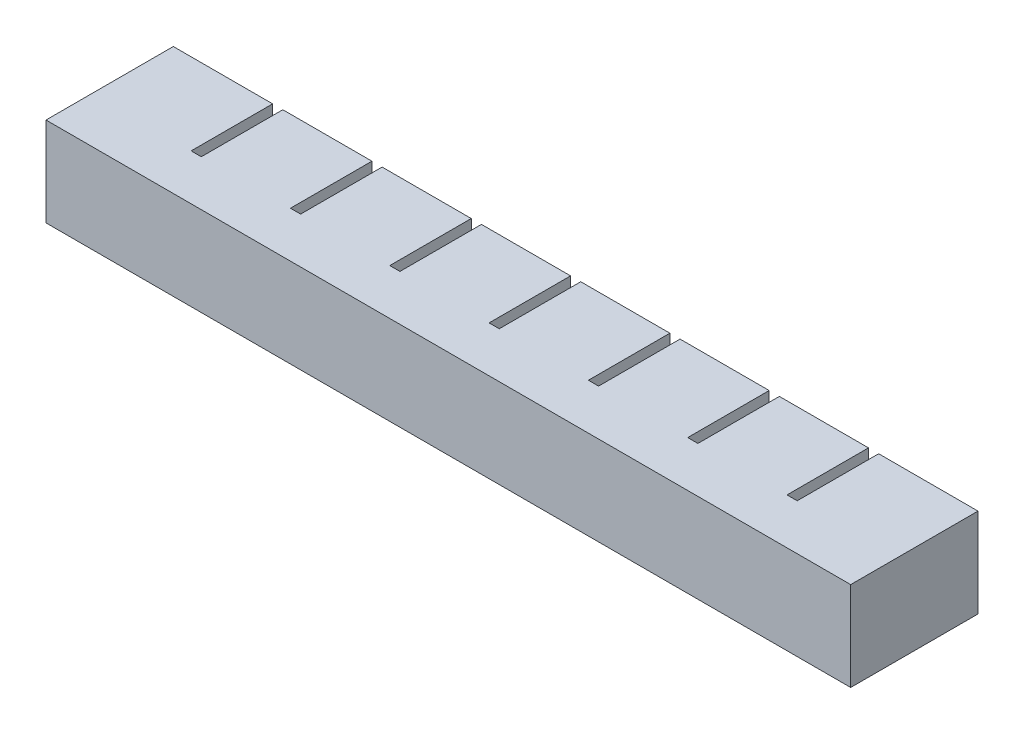
from build123d import *

# Parameters (mm, degrees)
SKETCH1_W           = 17.5
SKETCH1_H           = 17.5
BOSS_EXTRUDE1_DEPTH = 20
SKETCH2_W           = 11.5
SKETCH2_H           = 11.5
CUT_EXTRUDE1_DEPTH  = 17
SKETCH4_W           = 4
SKETCH4_H           = 17.5
BOSS_EXTRUDE2_DEPTH = 2
LPATTERN1_COUNT     = 8
LPATTERN1_PITCH     = 19.5
SKETCH5_W           = 16
SKETCH5_H           = 17.5
BOSS_EXTRUDE3_DEPTH = 2
SKETCH6_W           = 20
SKETCH6_H           = 17.5
BOSS_EXTRUDE4_DEPTH = 2
SKETCH7_W           = 125
SKETCH7_H           = 2.5
CUT_EXTRUDE2_DEPTH  = 2
SKETCH8_W           = 156
SKETCH8_H           = 15.5
SKETCH8_W_2         = 152.631082986
SKETCH8_H_2         = 13.5
BOSS_EXTRUDE5_DEPTH = 2
SKETCH9_W           = 156
SKETCH9_H           = 15.5
BOSS_EXTRUDE6_DEPTH = 2
SKETCH10_W          = 158
SKETCH10_H          = 17.5
BOSS_EXTRUDE7_DEPTH = 5


with BuildPart() as part:
    # Sketch1 → Boss-Extrude1 (new body)
    with BuildSketch(Plane.XY):
        with Locations((8.75, 8.75)):
            Rectangle(SKETCH1_W, SKETCH1_H)
    extrude(amount=BOSS_EXTRUDE1_DEPTH)

    # Sketch2 → Cut-Extrude1 (cut)
    with BuildSketch(Plane.XY.offset(20)):
        with Locations((8.75, 8.75)):
            Rectangle(SKETCH2_W, SKETCH2_H)
    extrude(amount=-CUT_EXTRUDE1_DEPTH, mode=Mode.SUBTRACT)

    # Sketch4 → Boss-Extrude2 (add)
    with BuildSketch(Plane.ZY):
        with Locations((18, 8.75)):
            Rectangle(SKETCH4_W, SKETCH4_H)
    extrude(amount=BOSS_EXTRUDE2_DEPTH)


with BuildPart() as lpattern1_1:
    # LPattern1: pattern copy
    add(part.part.moved(Location(Vector(-1, 0, 0) * (1 * LPATTERN1_PITCH))))


with BuildPart() as lpattern1_2:
    # LPattern1: pattern copy
    add(part.part.moved(Location(Vector(-1, 0, 0) * (2 * LPATTERN1_PITCH))))


with BuildPart() as lpattern1_3:
    # LPattern1: pattern copy
    add(part.part.moved(Location(Vector(-1, 0, 0) * (3 * LPATTERN1_PITCH))))


with BuildPart() as lpattern1_4:
    # LPattern1: pattern copy
    add(part.part.moved(Location(Vector(-1, 0, 0) * (4 * LPATTERN1_PITCH))))


with BuildPart() as lpattern1_5:
    # LPattern1: pattern copy
    add(part.part.moved(Location(Vector(-1, 0, 0) * (5 * LPATTERN1_PITCH))))


with BuildPart() as lpattern1_6:
    # LPattern1: pattern copy
    add(part.part.moved(Location(Vector(-1, 0, 0) * (6 * LPATTERN1_PITCH))))


with BuildPart() as lpattern1_7:
    # LPattern1: pattern copy
    add(part.part.moved(Location(Vector(-1, 0, 0) * (7 * LPATTERN1_PITCH))))


with BuildPart() as lpattern1_4_1:
    add(lpattern1_4.part)

    # Combine1: union LPattern1_5, LPattern1_6, LPattern1_7, LPattern1_1, LPattern1_2, part, LPattern1_3
    add(lpattern1_5.part)
    add(lpattern1_6.part)
    add(lpattern1_7.part)
    add(lpattern1_1.part)
    add(lpattern1_2.part)
    add(part.part)
    add(lpattern1_3.part)

    # Sketch5 → Boss-Extrude3 (add)
    with BuildSketch(Plane.ZY.offset(136.5)):
        with Locations((8, 8.75)):
            Rectangle(SKETCH5_W, SKETCH5_H)
    extrude(amount=BOSS_EXTRUDE3_DEPTH)

    # Sketch6 → Boss-Extrude4 (add)
    with BuildSketch(Plane(origin=(17.5, 0, 0), x_dir=(0, 0, -1), z_dir=(1, 0, 0))):
        with Locations((-10, 8.75)):
            Rectangle(SKETCH6_W, SKETCH6_H)
    extrude(amount=BOSS_EXTRUDE4_DEPTH)

    # Sketch7 → Cut-Extrude2 (cut)
    with BuildSketch(Plane.XY.offset(20)):
        with Locations((-59.5, 8.75)):
            Rectangle(SKETCH7_W, SKETCH7_H)
    extrude(amount=-CUT_EXTRUDE2_DEPTH, mode=Mode.SUBTRACT)

    # Sketch8 → Boss-Extrude5 (add)
    with BuildSketch(Plane.XY.offset(20)):
        with Locations((-59.5, 8.75)):
            Rectangle(SKETCH8_W, SKETCH8_H)
        with Locations((-59.5, 8.75)):
            Rectangle(SKETCH8_W_2, SKETCH8_H_2, mode=Mode.SUBTRACT)
    extrude(amount=BOSS_EXTRUDE5_DEPTH)

    # Sketch9 → Boss-Extrude6 (add)
    with BuildSketch(Plane.XY.offset(20)):
        with Locations((-59.5, 8.75)):
            Rectangle(SKETCH9_W, SKETCH9_H)
    extrude(amount=BOSS_EXTRUDE6_DEPTH)

    # Sketch10 → Boss-Extrude7 (add)
    with BuildSketch(Plane.XY.offset(20)):
        with Locations((-59.5, 8.75)):
            Rectangle(SKETCH10_W, SKETCH10_H)
    extrude(amount=BOSS_EXTRUDE7_DEPTH)


solid = lpattern1_4_1.part
